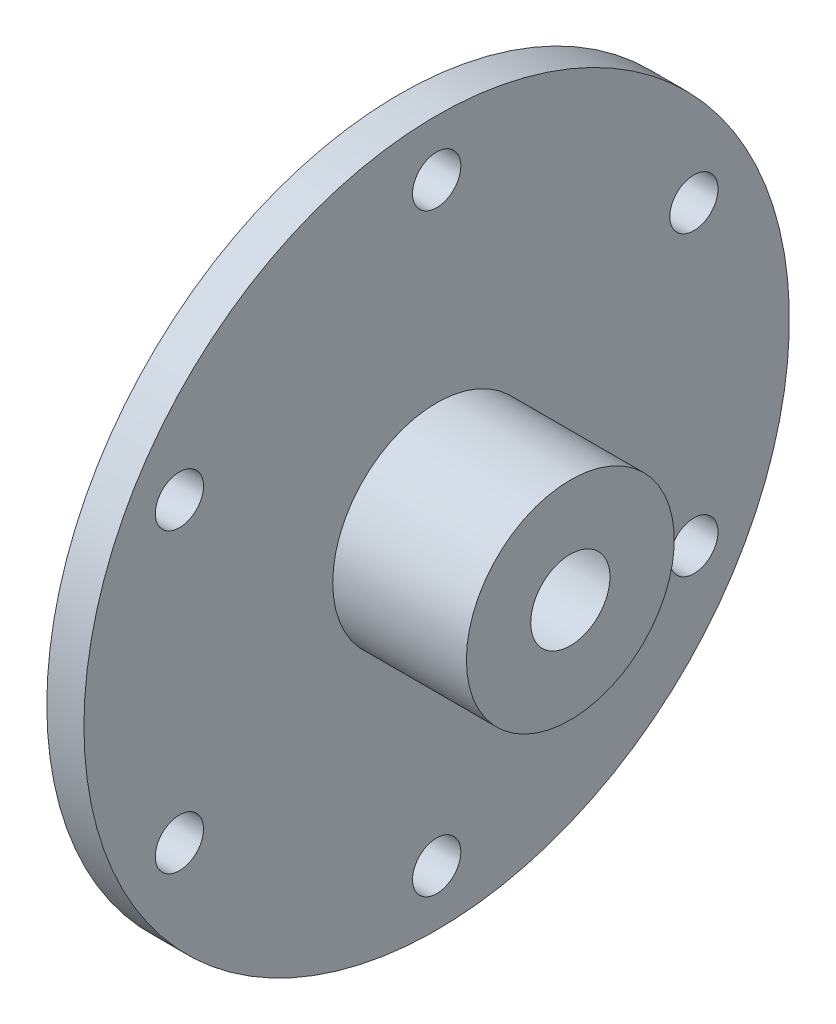
from build123d import *

# Parameters (mm, degrees)
CSK_FOR_M12_HEX_SOCKET_COUNTERSUNK_CAP_S_D           = 14
CSK_FOR_M12_HEX_SOCKET_COUNTERSUNK_CAP_S_DEPTH       = 27
CSK_FOR_M12_HEX_SOCKET_COUNTERSUNK_CAP_S_CSINK_D     = 26
CSK_FOR_M12_HEX_SOCKET_COUNTERSUNK_CAP_S_CSINK_ANGLE = 90
CSK_FOR_M12_HEX_SOCKET_COUNTERSUNK_CAP_S_TIP         = 4.206024333
CSK_FOR_M6_HEX_SOCKET_COUNTERSUNK_CAP_SC_D           = 6.5
CSK_FOR_M6_HEX_SOCKET_COUNTERSUNK_CAP_SC_CSINK_D     = 7.5
CSK_FOR_M6_HEX_SOCKET_COUNTERSUNK_CAP_SC_CSINK_ANGLE = 90
CIRPATTERN1_COUNT                                    = 6


with BuildPart() as part:
    # Sketch1 → Revolve1 (revolve)
    with BuildSketch(Plane.XY):
        Polygon((-20.025316456, 0), (-20.025316456, 35), (-15.025316456, 35), (-15.025316456, 47.5), (-10.025316456, 47.5), (-10.025316456, 14), (7.974683544, 14), (7.974683544, 0), align=None)
    revolve(axis=Axis((-20.025316456, 0, 0), (1, 0, 0)))

    # CSK for M12 Hex Socket Countersunk Cap Screw1
    with Locations(Plane.ZY.offset(20.025316456)):
        with Locations((0, 0)):
            CounterSinkHole(CSK_FOR_M12_HEX_SOCKET_COUNTERSUNK_CAP_S_D / 2, CSK_FOR_M12_HEX_SOCKET_COUNTERSUNK_CAP_S_CSINK_D / 2, depth=CSK_FOR_M12_HEX_SOCKET_COUNTERSUNK_CAP_S_DEPTH, counter_sink_angle=CSK_FOR_M12_HEX_SOCKET_COUNTERSUNK_CAP_S_CSINK_ANGLE)
            with Locations((0, 0, -(CSK_FOR_M12_HEX_SOCKET_COUNTERSUNK_CAP_S_DEPTH + CSK_FOR_M12_HEX_SOCKET_COUNTERSUNK_CAP_S_TIP / 2))):  # 118° drill point
                Cone(0, CSK_FOR_M12_HEX_SOCKET_COUNTERSUNK_CAP_S_D / 2, CSK_FOR_M12_HEX_SOCKET_COUNTERSUNK_CAP_S_TIP, mode=Mode.SUBTRACT)

    # CSK for M6 Hex Socket Countersunk Cap Screw1 (through all)
    with Locations(Plane.ZY.offset(20.025316456)):
        with Locations((0, 40)):
            csk_for_m6_hex_socket_countersunk_cap_sc = CounterSinkHole(CSK_FOR_M6_HEX_SOCKET_COUNTERSUNK_CAP_SC_D / 2, CSK_FOR_M6_HEX_SOCKET_COUNTERSUNK_CAP_SC_CSINK_D / 2, counter_sink_angle=CSK_FOR_M6_HEX_SOCKET_COUNTERSUNK_CAP_SC_CSINK_ANGLE)

    # CirPattern1: CSK for M6 Hex Socket Countersunk Cap Screw1 ×6 about axis
    cirpattern1_axis = Axis((0, 0, 0), (1, 0, 0))
    for i in range(1, CIRPATTERN1_COUNT):
        add(csk_for_m6_hex_socket_countersunk_cap_sc.rotate(cirpattern1_axis, i * 360 / CIRPATTERN1_COUNT), mode=Mode.SUBTRACT)


solid = part.part
